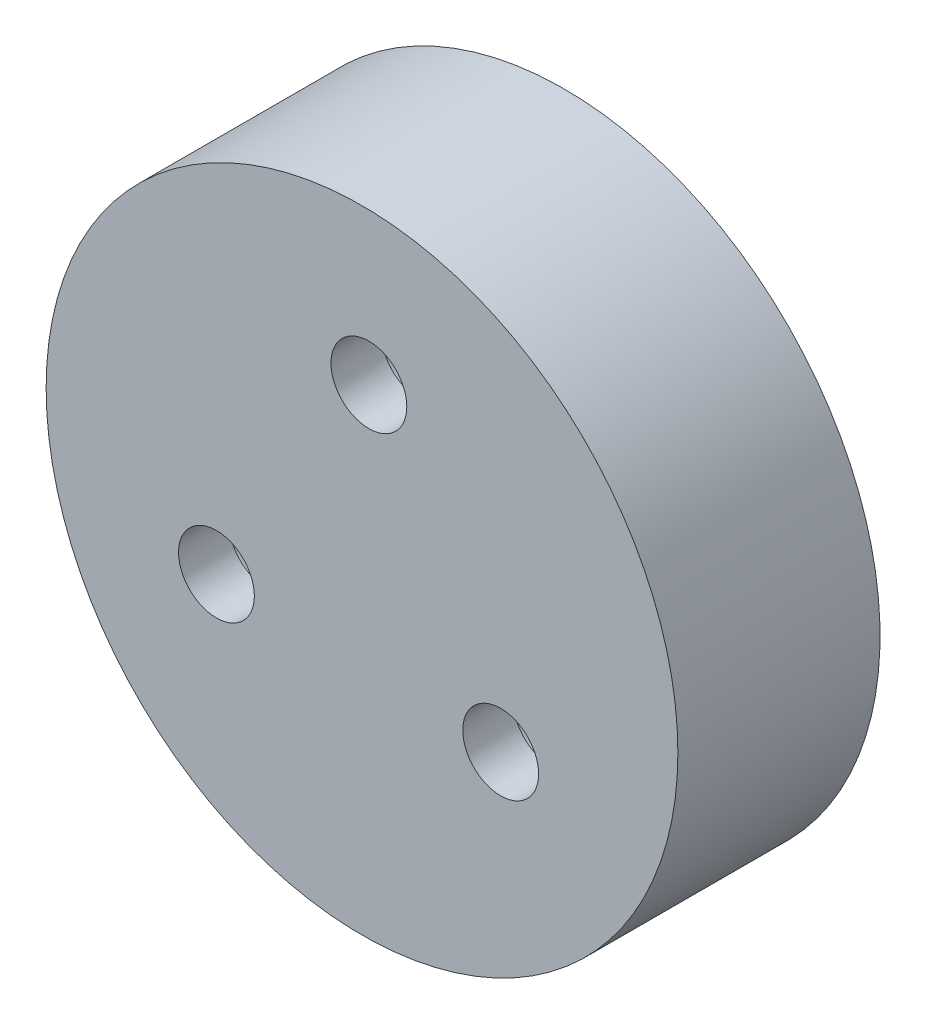
from build123d import *

# Parameters (mm, degrees)
SKETCH2_R           = 12.5
BOSS_EXTRUDE1_DEPTH = 6
SKETCH6_R           = 1.5
CUT_EXTRUDE1_DEPTH  = 15
SKETCH8_R           = 12.5
SKETCH8_R_2         = 10
BOSS_EXTRUDE2_DEPTH = 2
SKETCH9_R           = 2.5
CUT_EXTRUDE3_DEPTH  = 4


with BuildPart() as part:
    # Sketch2 → Boss-Extrude1 (new body)
    with BuildSketch(Plane.XY):
        Circle(SKETCH2_R)
    extrude(amount=BOSS_EXTRUDE1_DEPTH)

    # Sketch6 → Cut-Extrude1 (cut)
    with BuildSketch(Plane(origin=(0, 0, 0), x_dir=(-1, 0, 0), z_dir=(0, 0, -1))):
        with Locations((-5.488160471, -3.482828541)):
            Circle(SKETCH6_R)
        with Locations((-0.272137758, 6.494300658)):
            Circle(SKETCH6_R)
        with Locations((5.760298229, -3.011472117)):
            Circle(SKETCH6_R)
    extrude(amount=-CUT_EXTRUDE1_DEPTH, mode=Mode.SUBTRACT)

    # Sketch8 → Boss-Extrude2 (add)
    with BuildSketch(Plane(origin=(0, 0, 0), x_dir=(-1, 0, 0), z_dir=(0, 0, -1))):
        Circle(SKETCH8_R)
        Circle(SKETCH8_R_2, mode=Mode.SUBTRACT)
    extrude(amount=BOSS_EXTRUDE2_DEPTH)

    # Sketch9 → Cut-Extrude3 (cut)
    with BuildSketch(Plane(origin=(0, 0, 0), x_dir=(-1, 0, 0), z_dir=(0, 0, -1))):
        with Locations((-0.272137758, 6.494300658)):
            Circle(SKETCH9_R)
        with Locations((5.760298229, -3.011472117)):
            Circle(SKETCH9_R)
        with Locations((-5.488160471, -3.482828541)):
            Circle(SKETCH9_R)
    extrude(amount=-CUT_EXTRUDE3_DEPTH, mode=Mode.SUBTRACT)


solid = part.part
